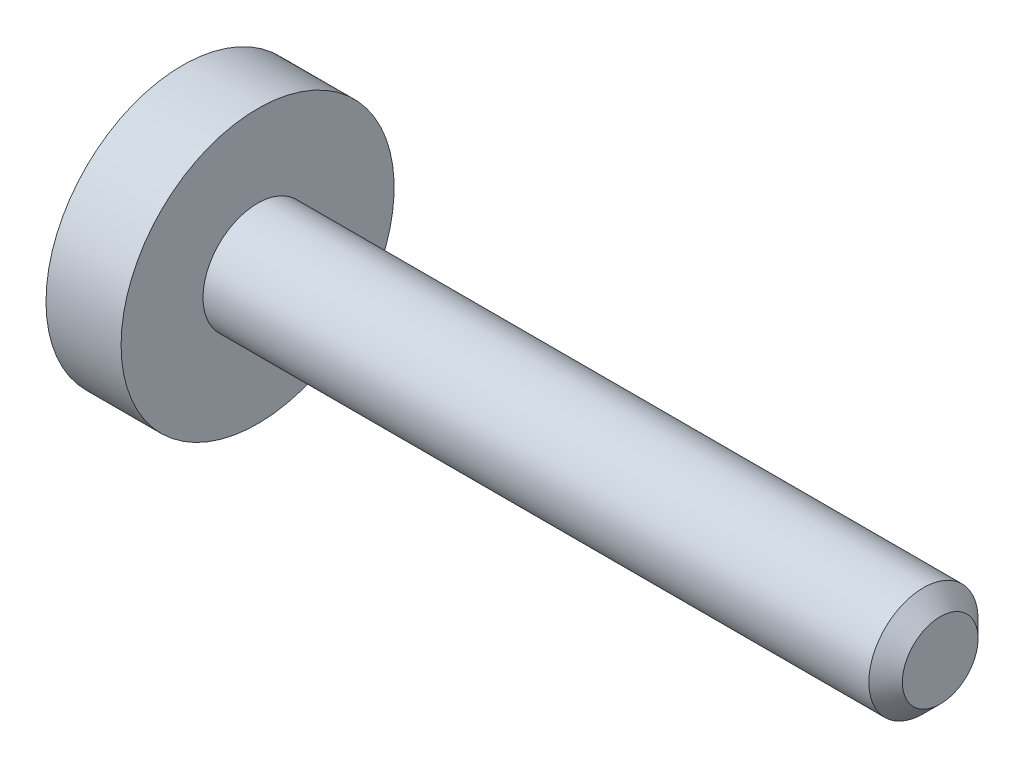
from build123d import *

# Parameters (mm, degrees)
CUT_EXTRUDE1_DEPTH = 1.2


with BuildPart() as part:
    # Sketch1 → Revolve1 (revolve)
    with BuildSketch(Plane.XY):
        Polygon((-1.1, 0), (-1.1, 2), (0, 2), (0, 0.8), (9.7545, 0.8), (10, 0.5545), (10, 0), align=None)
    revolve(axis=Axis((10, 0, 0), (-1, 0, 0)))

    # Sketch2 → Cut-Extrude1 (cut)
    with BuildSketch(Plane(origin=(-1.1, 0, 0), x_dir=(0, 0, -1), z_dir=(1, 0, 0))):
        Polygon((-0.65, -0.375277675), (0, -0.75055535), (0.65, -0.375277675), (0.65, 0.375277675), (0, 0.75055535), (-0.65, 0.375277675), align=None)
    extrude(amount=CUT_EXTRUDE1_DEPTH, mode=Mode.SUBTRACT)


solid = part.part
